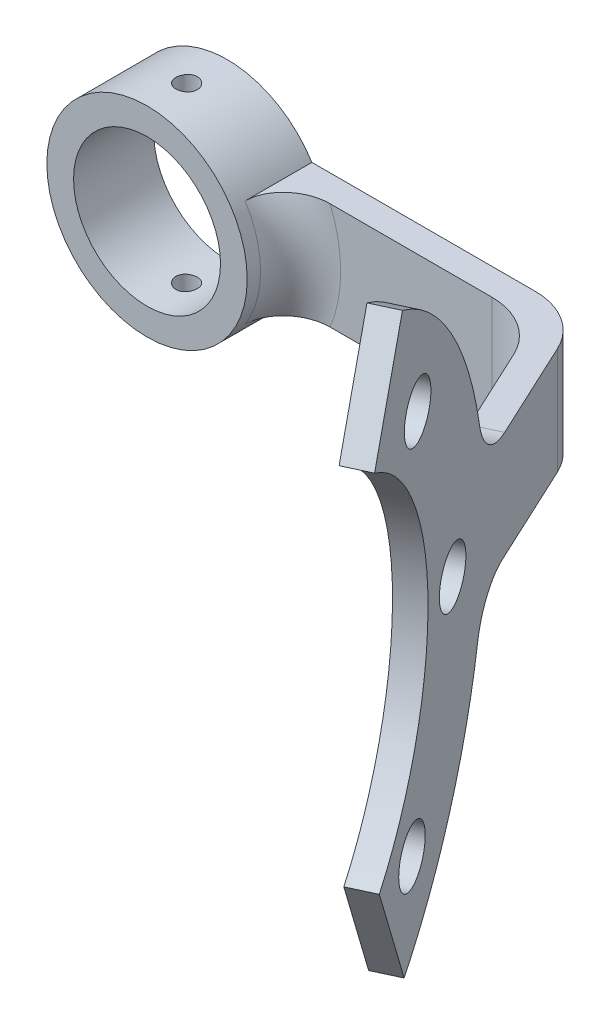
from build123d import *

# Parameters (mm, degrees)
BOSS_EXTRUDE1_DEPTH     = 8
FILLET1_R               = 5
BOSS_EXTRUDE2_DEPTH     = 2
SKETCH3_R               = 2.05
CUT_EXTRUDE3_DEPTH      = 10
CUT_EXTRUDE3_DEPTH_BACK = 10
FILLET2_R               = 4
SKETCH6_R               = 7.5
BOSS_EXTRUDE3_DEPTH     = 6
SKETCH2_R               = 5.5
CUT_EXTRUDE4_DEPTH      = 28.386006481
CUT_EXTRUDE4_DEPTH_BACK = 3
SKETCH8_R               = 0.8
CUT_EXTRUDE5_DEPTH      = 30.928860828
FILLET3_R               = 3


with BuildPart() as part:
    # Sketch1 → Boss-Extrude1 (new body)
    with BuildSketch(Plane(origin=(0, 0, 0), x_dir=(1, 0, 0), z_dir=(0, 1, 0))):
        Polygon((0, 0), (0, 2), (26.270067987, 2), (34.518104392, -15.687971152), (32.760161227, -16.641719455), (25, 0), align=None)
    extrude(amount=BOSS_EXTRUDE1_DEPTH)

    # Fillet1
    fillet1_edges = [part.edges().sort_by_distance(p)[0] for p in [
        (26.270067987, 4, -2),
        (25, 4, 0),
    ]]
    fillet(fillet1_edges, radius=FILLET1_R)

    # Sketch5 → Boss-Extrude2 (add)
    with BuildSketch(Plane(origin=(22.344115541, 0, -10.419232191), x_dir=(-0.422618262, 0, -0.906307787), z_dir=(0.906307787, 0, -0.422618262))):
        with BuildLine():
            Line((-40.780850255, 18.736062391), (-36.467218683, 26.428860828))
            ThreePointArc((-36.467218683, 26.428860828), (-23.692308478, 4.771999965), (-36.205658542, -17.037035395))
            Line((-36.205658542, -17.037035395), (-40.049339329, -9.057253488))
            ThreePointArc((-40.049339329, -9.057253488), (-32.517126315, 5.047276383), (-40.780850255, 18.736062391))
        make_face()
    extrude(amount=-BOSS_EXTRUDE2_DEPTH)

    # Sketch3 → Cut-Extrude3 (cut, two sides)
    with BuildSketch(Plane(origin=(20.534845121, 0, -9.575555539), x_dir=(0.422618262, 0, 0.906307787), z_dir=(-0.906307787, 0, 0.422618262))) as cut_extrude3_sk:
        with Locations((28.701516689, 4)):
            Circle(SKETCH3_R)
        with Locations((34.117040182, 18.317355913)):
            Circle(SKETCH3_R)
        with Locations((48.070293023, 24.611901983)):
            Circle(SKETCH3_R)
        with Locations((62.387648936, 19.19637849)):
            Circle(SKETCH3_R)
        with Locations((68.682195005, 5.243125649)):
            Circle(SKETCH3_R)
        with Locations((63.266671512, -9.074230264)):
            Circle(SKETCH3_R)
        with Locations((49.313418672, -15.368776333)):
            Circle(SKETCH3_R)
        with Locations((34.996062759, -9.953252841)):
            Circle(SKETCH3_R)
    extrude(amount=CUT_EXTRUDE3_DEPTH, mode=Mode.SUBTRACT)
    extrude(cut_extrude3_sk.sketch, amount=-CUT_EXTRUDE3_DEPTH_BACK, mode=Mode.SUBTRACT)

    # Fillet2
    fillet2_edges = [part.edges().sort_by_distance(p)[0] for p in [
        (31.634193328, 0, 11.865238709),
        (31.549009715, 8, 11.682561863),
    ]]
    fillet(fillet2_edges, radius=FILLET2_R)

    # Sketch6 → Boss-Extrude3 (add)
    with BuildSketch(Plane(origin=(0, 0, -2), x_dir=(-1, 0, 0), z_dir=(0, 0, -1))):
        with Locations((0, 4)):
            Circle(SKETCH6_R)
    extrude(amount=-BOSS_EXTRUDE3_DEPTH)

    # Sketch2 → Cut-Extrude4 (cut, two sides)
    with BuildSketch(Plane.XY) as cut_extrude4_sk:
        with Locations((0, 4)):
            Circle(SKETCH2_R)
    extrude(amount=CUT_EXTRUDE4_DEPTH, mode=Mode.SUBTRACT)
    extrude(cut_extrude4_sk.sketch, amount=-CUT_EXTRUDE4_DEPTH_BACK, mode=Mode.SUBTRACT)

    # Sketch8 → Cut-Extrude5 (cut, through all)
    with BuildSketch(Plane(origin=(0, -3.5, 0), x_dir=(-1, 0, 0), z_dir=(0, -1, 0))):
        with Locations((0, -1.034043254)):
            Circle(SKETCH8_R)
    extrude(amount=-CUT_EXTRUDE5_DEPTH, mode=Mode.SUBTRACT)

    # Fillet3
    fillet3_edges = [part.edges().sort_by_distance(p)[0] for p in [
        (7.5, 4, 0),
    ]]
    fillet(fillet3_edges, radius=FILLET3_R)


solid = part.part
